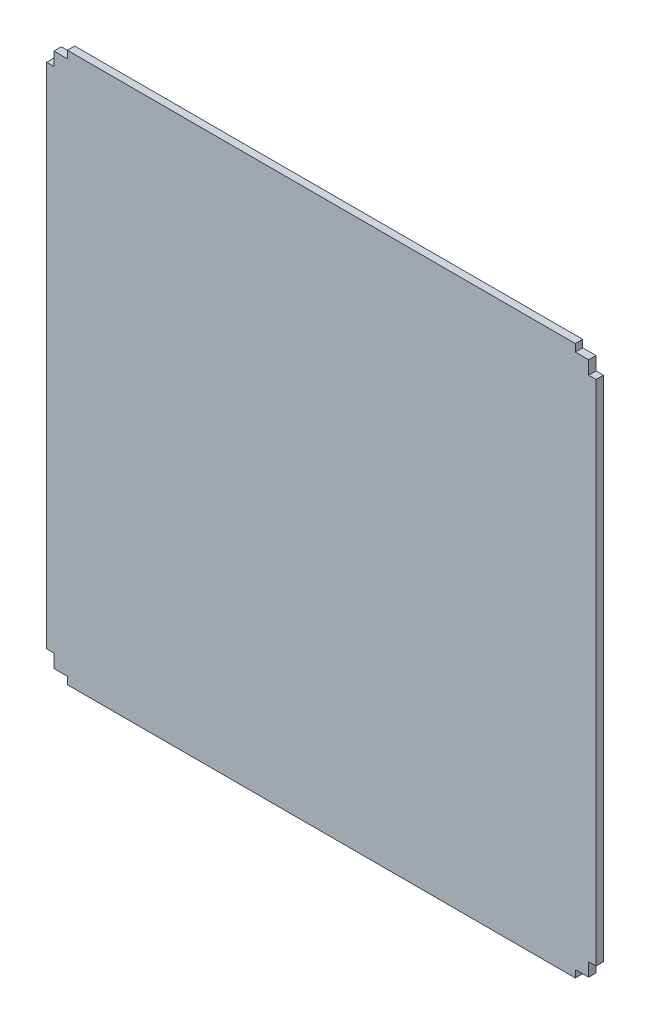
from build123d import *

# Parameters (mm, degrees)
EXTRUDE_1_DEPTH = 2.75


with BuildPart() as part:
    # 草图1 → 凸台-拉伸1 (new body)
    with BuildSketch(Plane.XY):
        Polygon((0, 0), (5, 0), (5, -2.75), (195, -2.75), (195, 0), (200, 0), (200, 5), (202.75, 5), (202.75, 195), (200, 195), (200, 200), (195, 200), (195, 202.75), (5, 202.75), (5, 200), (0, 200), (0, 195), (-2.75, 195), (-2.75, 5), (0, 5), align=None)
    extrude(amount=EXTRUDE_1_DEPTH)


solid = part.part
